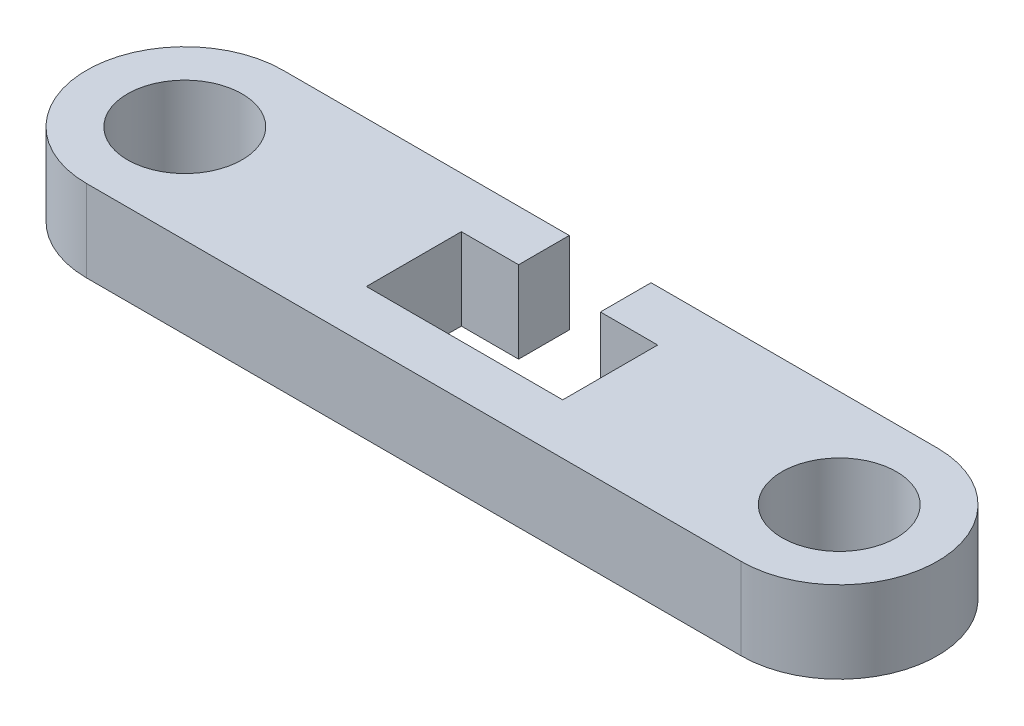
from build123d import *

# Parameters (mm, degrees)
SKETCH1_R           = 3
SKETCH1_R_2         = 1.75
BOSS_EXTRUDE1_DEPTH = 2.5


with BuildPart() as part:
    # Sketch1 → Boss-Extrude1 (new body)
    with BuildSketch(Plane(origin=(0, 0, 0), x_dir=(1, 0, 0), z_dir=(0, 1, 0))):
        with Locations((-6.5, 2)):
            Circle(SKETCH1_R)
        with Locations((-6.5, 2)):
            Circle(SKETCH1_R_2, mode=Mode.SUBTRACT)
        with BuildLine():
            Line((7, 0), (0, 0))
            Line((0, 0), (0, 4))
            Line((0, 4), (2.25, 4))
            Line((2.25, 4), (2.25, 5))
            Line((2.25, 5), (-6.5, 5))
            ThreePointArc((-6.5, 5), (-4.378679656, 4.121320344), (-3.5, 2))
            ThreePointArc((-3.5, 2), (-4.378679656, -0.121320344), (-6.5, -1))
            Line((-6.5, -1), (13.5, -1))
            ThreePointArc((13.5, -1), (10.5, 2), (13.5, 5))
            Line((13.5, 5), (4.75, 5))
            Line((4.75, 5), (4.75, 4))
            Line((4.75, 4), (7, 4))
            Line((7, 4), (7, 0))
        make_face()
        Polygon((2.25, 4), (0, 4), (0, 0), (7, 0), (7, 4), (4.75, 4), (4.75, 3.451807229), (6.5, 3.451807229), (6.5, 0.55), (0.5, 0.55), (0.5, 3.451807229), (2.25, 3.451807229), align=None)
        with Locations((13.5, 2)):
            Circle(SKETCH1_R)
        with Locations((13.5, 2)):
            Circle(SKETCH1_R_2, mode=Mode.SUBTRACT)
    extrude(amount=BOSS_EXTRUDE1_DEPTH)


solid = part.part
